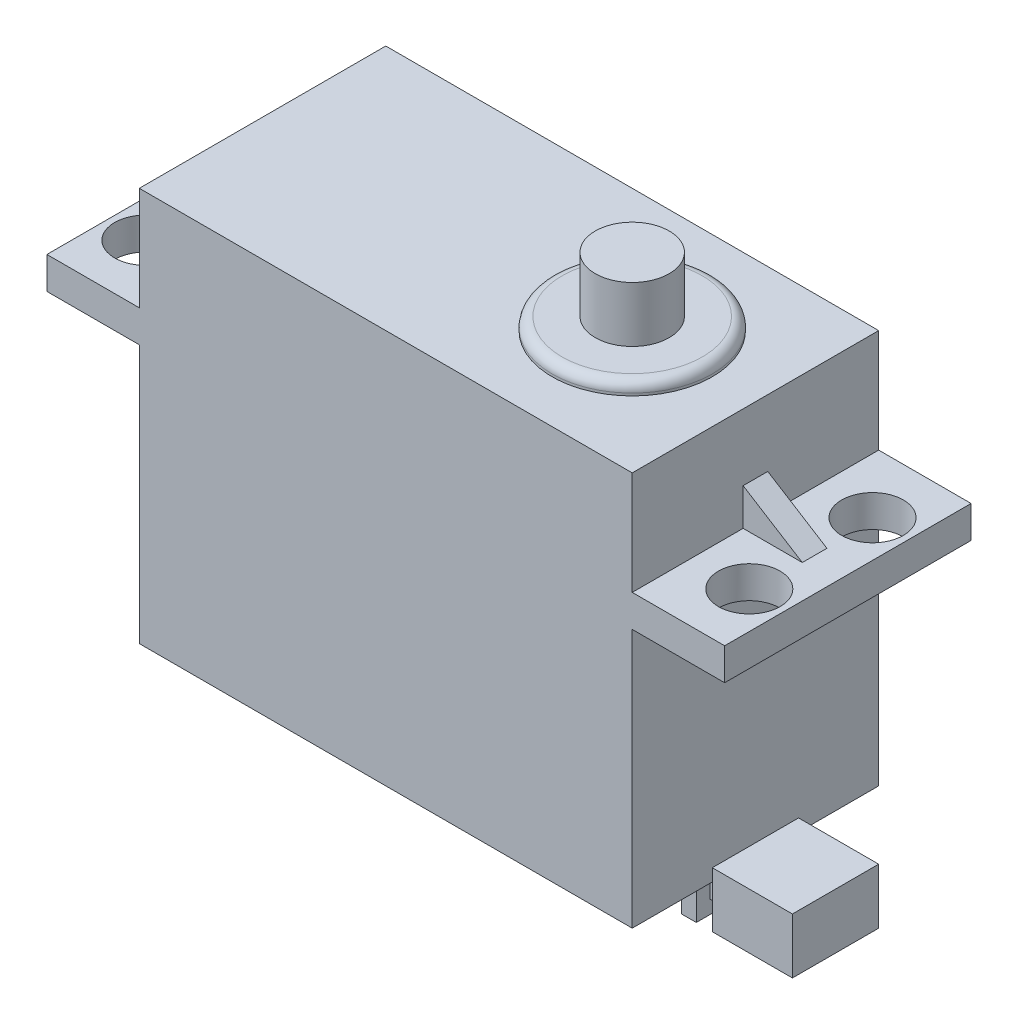
from build123d import *

# Parameters (mm, degrees)
ESQUISSE1_W             = 40
ESQUISSE1_H             = 32
EXTRUSION1_DEPTH        = 10
ESQUISSE2_R             = 6.5
EXTRUSION2_DEPTH        = 1
CONG_1_R                = 0.8
ESQUISSE3_R             = 3
EXTRUSION3_DEPTH        = 4.5
ESQUISSE4_W             = 9
ESQUISSE4_H             = 7
EXTRUSION4_DEPTH        = 3.5
EXTRUSION4_DEPTH_BACK   = 1
ESQUISSE5_W             = 1.3
ESQUISSE5_H             = 1.1
ENL_V_MAT_EXTRU_2_DEPTH = 3.5
ENL_V_MAT_EXTRU_5_REACH = 14.4
ESQUISSE9_W             = 1.3
ESQUISSE9_H             = 1.1
ESQUISSE7_R             = 1
ENL_V_MAT_EXTRU_4_DEPTH = 4.5
ESQUISSE8_W             = 7.5
ESQUISSE8_H             = 2.6
EXTRUSION6_DEPTH        = 20
EXTRUSION7_DEPTH        = 1
ENL_V_MAT_EXTRU_6_REACH = 29.1
ESQUISSE11_R            = 2.5


with BuildPart() as part:
    # Esquisse1 → Extrusion1 (new body, symmetric)
    with BuildSketch(Plane.XY):
        with Locations((20, 16)):
            Rectangle(ESQUISSE1_W, ESQUISSE1_H)
    extrude(amount=EXTRUSION1_DEPTH, both=True)

    # Esquisse2 → Extrusion2 (add)
    with BuildSketch(Plane(origin=(0, 32, 0), x_dir=(-1, 0, 0), z_dir=(0, 1, 0))):
        with Locations((-30, 0)):
            Circle(ESQUISSE2_R)
    extrude(amount=EXTRUSION2_DEPTH)

    # Cong_1
    cong_1_edges = [part.edges().sort_by_distance(p)[0] for p in [
        (36.5, 33, 0),
    ]]
    fillet(cong_1_edges, radius=CONG_1_R)

    # Esquisse3 → Extrusion3 (add)
    with BuildSketch(Plane(origin=(0, 33, 0), x_dir=(-1, 0, 0), z_dir=(0, 1, 0))):
        with Locations((-30, 0)):
            Circle(ESQUISSE3_R)
    extrude(amount=EXTRUSION3_DEPTH)

    # Esquisse4 → Extrusion4 (add, two sides)
    with BuildSketch(Plane.XZ) as extrusion4_sk:
        with Locations((42, 0)):
            Rectangle(ESQUISSE4_W, ESQUISSE4_H)
    extrude(amount=EXTRUSION4_DEPTH)
    extrude(extrusion4_sk.sketch, amount=-EXTRUSION4_DEPTH_BACK)

    # Esquisse5 → Enl_v. mat.-Extru.2 (cut)
    with BuildSketch(Plane.XZ.offset(3.5)):
        with Locations((39.35, 2.95)):
            Rectangle(ESQUISSE5_W, ESQUISSE5_H)
        with Locations((39.35, -2.95)):
            Rectangle(ESQUISSE5_W, ESQUISSE5_H)
    extrude(amount=-ENL_V_MAT_EXTRU_2_DEPTH, mode=Mode.SUBTRACT)

    # Esquisse9 → Enl_v. mat.-Extru.5 (cut, up to next)
    with BuildSketch(Plane(origin=(0, 0, -2.4), x_dir=(-1, 0, 0), z_dir=(0, 0, -1)), mode=Mode.PRIVATE) as enl_v_mat_extru_5_sk1:
        with Locations((-39.35, -2.95)):
            Rectangle(ESQUISSE9_W, ESQUISSE9_H)
    enl_v_mat_extru_5_tool1 = extrude(enl_v_mat_extru_5_sk1.sketch, amount=-ENL_V_MAT_EXTRU_5_REACH, mode=Mode.PRIVATE) & part.part
    add(enl_v_mat_extru_5_tool1.solids().sort_by_distance((39.35, -2.95, -2.4))[0], mode=Mode.SUBTRACT)

    # Esquisse7 → Enl_v. mat.-Extru.4 (cut)
    with BuildSketch(Plane.XZ):
        with Locations((37.3, -7.3)):
            Circle(ESQUISSE7_R)
        with Locations((2.7, -7.3)):
            Circle(ESQUISSE7_R)
        with Locations((2.7, 7.3)):
            Circle(ESQUISSE7_R)
        with Locations((37.3, 7.3)):
            Circle(ESQUISSE7_R)
    extrude(amount=-ENL_V_MAT_EXTRU_4_DEPTH, mode=Mode.SUBTRACT)

    # Esquisse8 → Extrusion6 (add)
    with BuildSketch(Plane.XY.offset(10)):
        with Locations((43.75, 22.3)):
            Rectangle(ESQUISSE8_W, ESQUISSE8_H)
        with Locations((-3.75, 22.3)):
            Rectangle(ESQUISSE8_W, ESQUISSE8_H)
    extrude(amount=-EXTRUSION6_DEPTH)

    # Esquisse10 → Extrusion7 (add, symmetric)
    with BuildSketch(Plane.XY):
        Polygon((40, 26.6), (40, 23.6), (44.8, 23.6), align=None)
        Polygon((-4.8, 23.6), (0, 23.6), (0, 26.6), align=None)
    extrude(amount=EXTRUSION7_DEPTH, both=True)

    # Esquisse11 → Enl_v. mat.-Extru.6 (cut, up to next)
    with BuildSketch(Plane(origin=(0, 23.6, 0), x_dir=(-1, 0, 0), z_dir=(0, 1, 0)), mode=Mode.PRIVATE) as enl_v_mat_extru_6_sk1:
        with Locations((-44.5, 5)):
            Circle(ESQUISSE11_R)
    enl_v_mat_extru_6_tool1 = extrude(enl_v_mat_extru_6_sk1.sketch, amount=-ENL_V_MAT_EXTRU_6_REACH, mode=Mode.PRIVATE) & part.part
    add(enl_v_mat_extru_6_tool1.solids().sort_by_distance((44.5, 23.6, 5))[0], mode=Mode.SUBTRACT)
    # Esquisse11 → Enl_v. mat.-Extru.6 (cut, up to next)
    with BuildSketch(Plane(origin=(0, 23.6, 0), x_dir=(-1, 0, 0), z_dir=(0, 1, 0)), mode=Mode.PRIVATE) as enl_v_mat_extru_6_sk2:
        with Locations((-44.5, -5)):
            Circle(ESQUISSE11_R)
    enl_v_mat_extru_6_tool2 = extrude(enl_v_mat_extru_6_sk2.sketch, amount=-ENL_V_MAT_EXTRU_6_REACH, mode=Mode.PRIVATE) & part.part
    add(enl_v_mat_extru_6_tool2.solids().sort_by_distance((44.5, 23.6, -5))[0], mode=Mode.SUBTRACT)
    # Esquisse11 → Enl_v. mat.-Extru.6 (cut, up to next)
    with BuildSketch(Plane(origin=(0, 23.6, 0), x_dir=(-1, 0, 0), z_dir=(0, 1, 0)), mode=Mode.PRIVATE) as enl_v_mat_extru_6_sk3:
        with Locations((4.5, -5)):
            Circle(ESQUISSE11_R)
    enl_v_mat_extru_6_tool3 = extrude(enl_v_mat_extru_6_sk3.sketch, amount=-ENL_V_MAT_EXTRU_6_REACH, mode=Mode.PRIVATE) & part.part
    add(enl_v_mat_extru_6_tool3.solids().sort_by_distance((-4.5, 23.6, -5))[0], mode=Mode.SUBTRACT)
    # Esquisse11 → Enl_v. mat.-Extru.6 (cut, up to next)
    with BuildSketch(Plane(origin=(0, 23.6, 0), x_dir=(-1, 0, 0), z_dir=(0, 1, 0)), mode=Mode.PRIVATE) as enl_v_mat_extru_6_sk4:
        with Locations((4.5, 5)):
            Circle(ESQUISSE11_R)
    enl_v_mat_extru_6_tool4 = extrude(enl_v_mat_extru_6_sk4.sketch, amount=-ENL_V_MAT_EXTRU_6_REACH, mode=Mode.PRIVATE) & part.part
    add(enl_v_mat_extru_6_tool4.solids().sort_by_distance((-4.5, 23.6, 5))[0], mode=Mode.SUBTRACT)


solid = part.part
